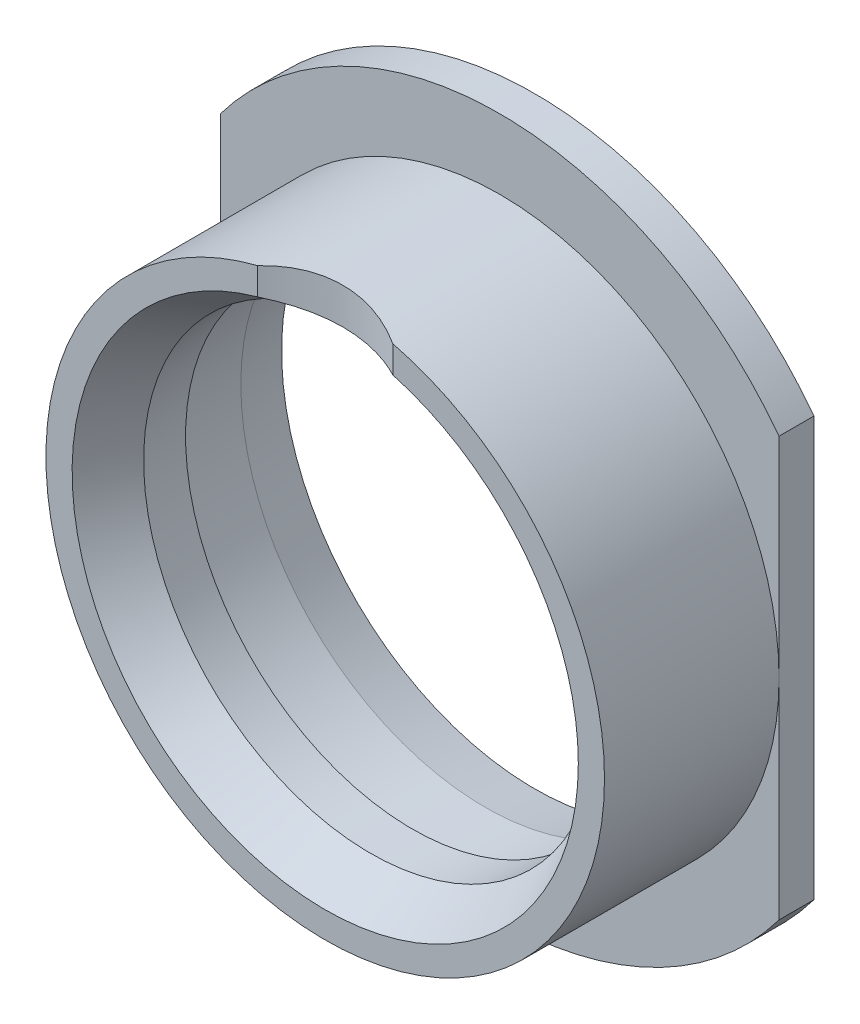
from build123d import *

# Parameters (mm, degrees)
CUT_EXTRUDE_1_DEPTH      = 11
CUT_EXTRUDE_1_DEPTH_BACK = 3
CUT_EXTRUDE_2_DEPTH      = 21


with BuildPart() as part:
    # Эскиз1 → Повернуть1 (revolve)
    with BuildSketch(Plane(origin=(0, 0, 0), x_dir=(0, 0, -1), z_dir=(1, 0, 0))):
        Polygon((2.598076211, 13), (5, 13), (5, 14), (9.16435909, 14), (12, 14.5), (12, 20), (10, 20), (10, 16), (0, 16), (0, 14.5), align=None)
    revolve(axis=Axis((0, 0, 0), (0, 0, -1)))

    # Эскиз2 → Вырез-Вытянуть1 (cut, two sides)
    with BuildSketch(Plane.XY.offset(-10)) as cut_extrude_1_sk:
        with BuildLine():
            Line((-16, -12), (-16, 12))
            ThreePointArc((-16, 12), (-20, 0), (-16, -12))
        make_face()
        with BuildLine():
            ThreePointArc((20, 0), (18.973665961, 6.32455532), (16, 12))
            Line((16, 12), (16, -12))
            ThreePointArc((16, -12), (18.973665961, -6.32455532), (20, 0))
        make_face()
    extrude(amount=CUT_EXTRUDE_1_DEPTH, mode=Mode.SUBTRACT)
    extrude(cut_extrude_1_sk.sketch, amount=-CUT_EXTRUDE_1_DEPTH_BACK, mode=Mode.SUBTRACT)

    # Эскиз3 → Вырез-Вытянуть2 (cut, through all)
    with BuildSketch(Plane(origin=(0, 0, 0), x_dir=(1, 0, 0), z_dir=(0, 1, 0))):
        with BuildLine():
            Line((-53.249204779, -27.319040473), (-3.872983346, 0))
            ThreePointArc((-3.872983346, 0), (0, 1), (3.872983346, 0))
            Line((3.872983346, 0), (53.249204779, -27.319040473))
            Line((53.249204779, -27.319040473), (53.249204779, -140.178975177))
            Line((53.249204779, -140.178975177), (-53.249204779, -140.178975177))
            Line((-53.249204779, -140.178975177), (-53.249204779, -27.319040473))
        make_face()
    extrude(amount=CUT_EXTRUDE_2_DEPTH, mode=Mode.SUBTRACT)


solid = part.part
